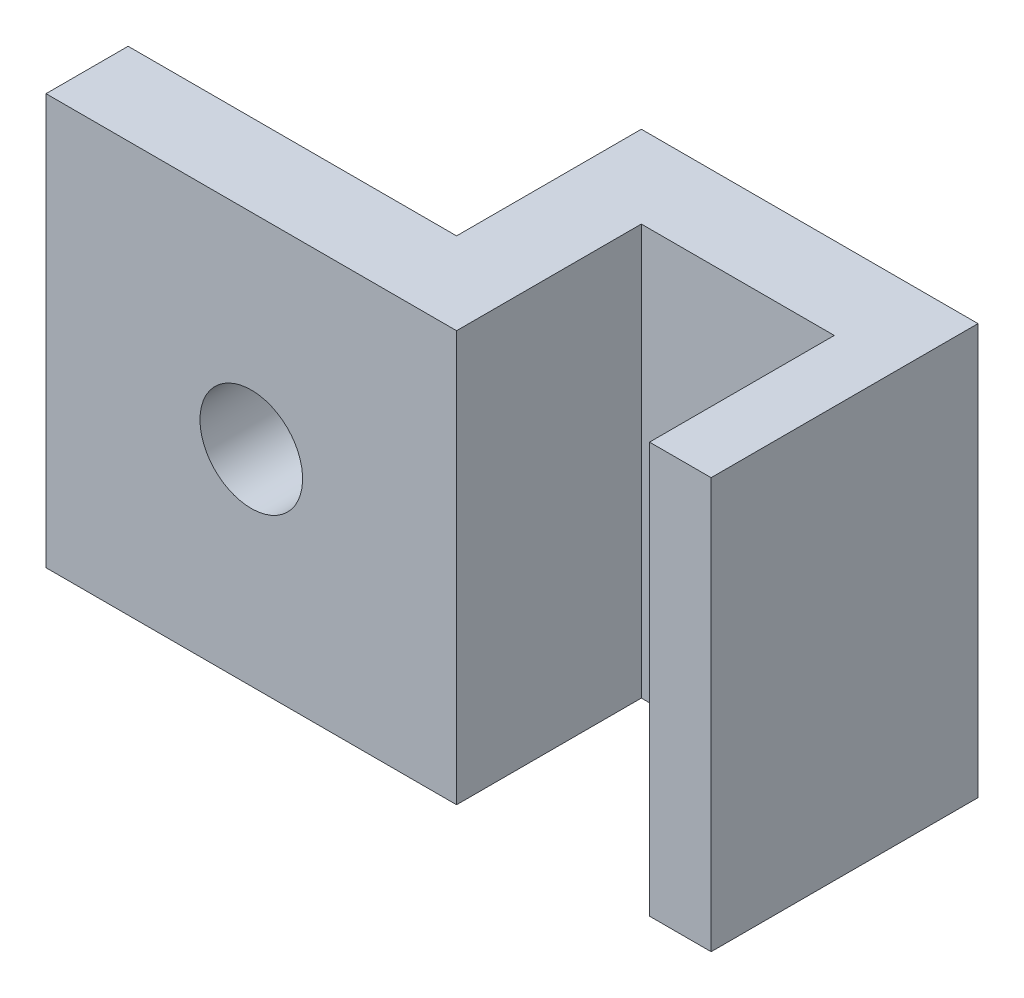
from build123d import *

# Parameters (mm, degrees)
SALIENTE_EXTRUIR1_DEPTH = 10
CROQUIS2_R              = 1.25
CORTAR_EXTRUIR1_DEPTH   = 10
CROQUIS3_W              = 2
CROQUIS3_H              = 10
SALIENTE_EXTRUIR2_DEPTH = 2


with BuildPart() as part:
    # Croquis1 → Saliente-Extruir1 (new body)
    with BuildSketch(Plane(origin=(0, 0, 0), x_dir=(1, 0, 0), z_dir=(0, 1, 0))):
        Polygon((0, 0), (8, 0), (8, 4.5), (12.7, 4.5), (12.7, 0), (14.2, 0), (14.2, 6.5), (6, 6.5), (6, 2), (0, 2), align=None)
    extrude(amount=SALIENTE_EXTRUIR1_DEPTH)

    # Croquis2 → Cortar-Extruir1 (cut)
    with BuildSketch(Plane(origin=(0, 0, -2), x_dir=(-1, 0, 0), z_dir=(0, 0, -1))):
        with Locations((-3, 5)):
            Circle(CROQUIS2_R)
    extrude(amount=-CORTAR_EXTRUIR1_DEPTH, mode=Mode.SUBTRACT)

    # Croquis3 → Saliente-Extruir2 (add)
    with BuildSketch(Plane.ZY):
        with Locations((-1, 5)):
            Rectangle(CROQUIS3_W, CROQUIS3_H)
    extrude(amount=SALIENTE_EXTRUIR2_DEPTH)


solid = part.part
